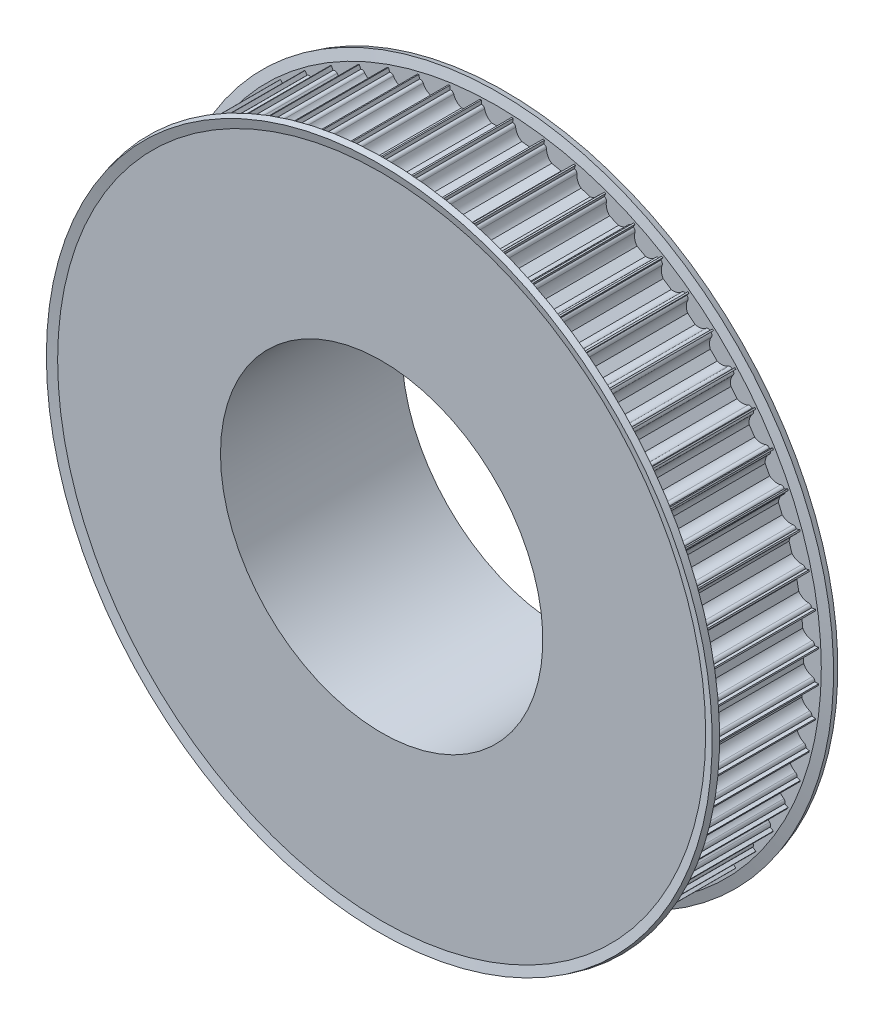
from build123d import *

# Parameters (mm, degrees)
CORTAR_EXTRUIR1_DEPTH = 46
MATRIZC1_COUNT        = 64


with BuildPart() as part:
    # Croquis1 → Revolución1 (revolve)
    with BuildSketch(Plane(origin=(0, 0, 0), x_dir=(0, 0, -1), z_dir=(1, 0, 0))):
        Polygon((0, 40), (0, 80), (30, 80), (30, 55.5), (45, 55.5), (45, 40), align=None)
    revolve(axis=Axis((0, 0, -88.99), (0, 0, 1)))

    # Croquis2 → Cortar-Extruir1 (cut, through all)
    with BuildSketch(Plane.XY):
        with BuildLine():
            Line((3.674234614, 79), (3.75, 79))
            Line((3.75, 79), (3.75, 81))
            Line((3.75, 81), (-3.75, 81))
            Line((-3.75, 81), (-3.75, 79))
            Line((-3.75, 79), (-3.674234614, 79))
            ThreePointArc((-3.674234614, 79), (-3.199892965, 78.830947502), (-2.939387691, 78.4))
            ThreePointArc((-2.939387691, 78.4), (-2.331759211, 77.112435701), (-1.198957881, 76.25))
            Line((-1.198957881, 76.25), (1.198957881, 76.25))
            ThreePointArc((1.198957881, 76.25), (2.331759211, 77.112435701), (2.939387691, 78.4))
            ThreePointArc((2.939387691, 78.4), (3.199892965, 78.830947502), (3.674234614, 79))
        make_face()
    cortar_extruir1 = extrude(amount=-CORTAR_EXTRUIR1_DEPTH, mode=Mode.SUBTRACT)

    # MatrizC1: Cortar-Extruir1 ×64 about axis
    matrizc1_axis = Axis((0, 0, 0), (0, 0, 1))
    for i in range(1, MATRIZC1_COUNT):
        add(cortar_extruir1.rotate(matrizc1_axis, i * 360 / MATRIZC1_COUNT), mode=Mode.SUBTRACT)

    # Croquis4 → Revolución2 (revolve)
    with BuildSketch(Plane(origin=(0, 0, 0), x_dir=(0, 0, -1), z_dir=(1, 0, 0))):
        Polygon((0, 80.414582296), (0, 75.612061042), (1.5, 75.612061042), (1.5, 80.612061042), (0.856921938, 83.012061042), (-0.591966801, 82.623832474), align=None)
        Polygon((30.591966801, 82.623832474), (29.143078062, 83.012061042), (28.5, 80.612061042), (28.5, 75.612061042), (30, 75.612061042), (30, 80.414582296), align=None)
    revolve(axis=Axis((0, 0, -88.99), (0, 0, 1)))


solid = part.part
